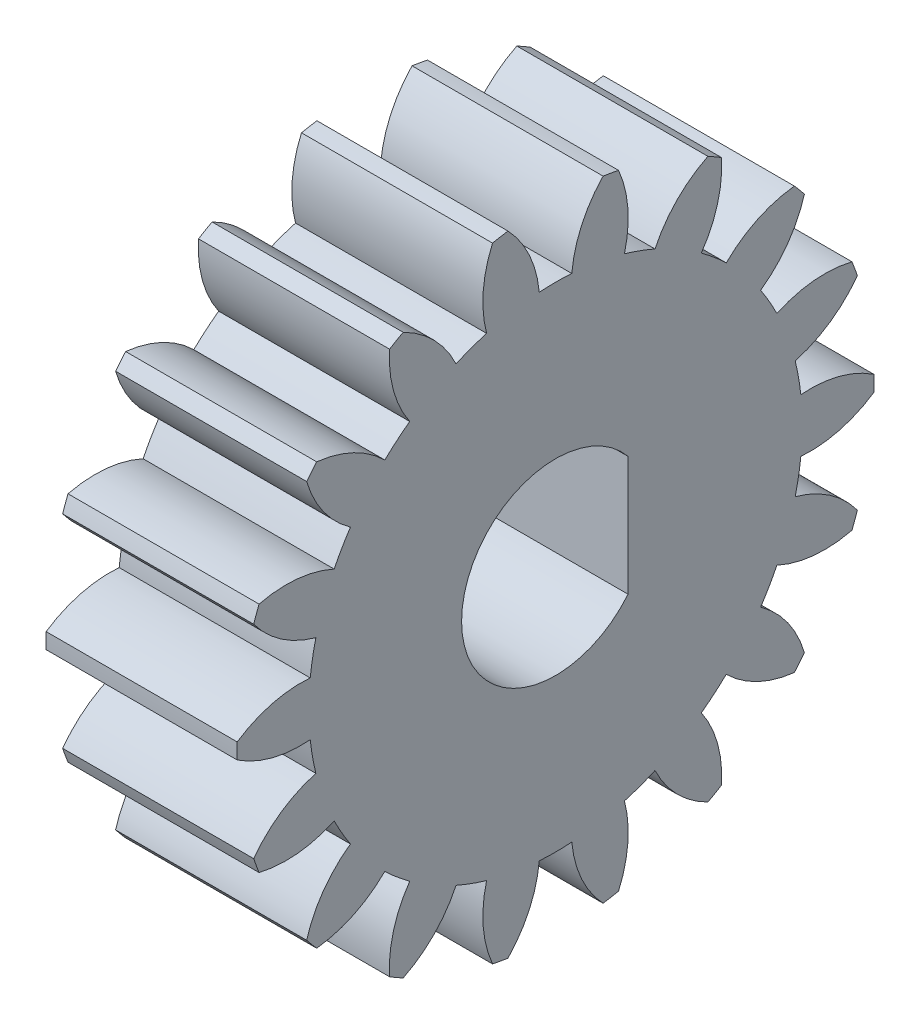
from build123d import *

# Parameters (mm, degrees)
BASPROSKE_W        = 6
BASPROSKE_H        = 10
TOOTHCUT_DEPTH     = 16.362291496
TEETHCUTS_COUNT    = 18
TEETHCUTS_ANGLE    = 340
CUT_EXTRUDE1_DEPTH = 16.289512146


with BuildPart() as part:
    # BasProSke → Base-Revolve (revolve)
    with BuildSketch(Plane(origin=(0, 0, 0), x_dir=(1, 0, 0), z_dir=(0, 1, 0)), mode=Mode.PRIVATE) as base_revolve_sk:
        with Locations((3, 5)):
            Rectangle(BASPROSKE_W, BASPROSKE_H)
    revolve(base_revolve_sk.sketch.rotate(Axis((-10, 0, 0), (1, 0, 0)), 180), axis=Axis((-10, 0, 0), (1, 0, 0)))

    # TooCutSke → ToothCut (cut, through all)
    with BuildSketch(Plane(origin=(0, 0, 0), x_dir=(0, 0, -1), z_dir=(1, 0, 0))):
        with BuildLine():
            ThreePointArc((0.510641536, 7.732156635), (0, 7.749), (-0.510641536, 7.732156635))
            ThreePointArc((-0.510641536, 7.732156635), (-0.82619259, 8.907320741), (-1.515208602, 9.910236529))
            ThreePointArc((-1.515208602, 9.910236529), (0, 10.0254), (1.515208602, 9.910236529))
            ThreePointArc((1.515208602, 9.910236529), (0.82619259, 8.907320741), (0.510641536, 7.732156635))
        make_face()
    toothcut = extrude(amount=TOOTHCUT_DEPTH, mode=Mode.SUBTRACT)

    # TeethCuts: ToothCut ×18 about axis
    teethcuts_axis = Axis((-10, 0, 0), (1, 0, 0))
    for i in range(1, TEETHCUTS_COUNT):
        add(toothcut.rotate(teethcuts_axis, i * TEETHCUTS_ANGLE / (TEETHCUTS_COUNT - 1)), mode=Mode.SUBTRACT)

    # Sketch1 → Cut-Extrude1 (cut, through all)
    with BuildSketch(Plane(origin=(6, 0, 0), x_dir=(0, 0, -1), z_dir=(1, 0, 0))):
        with BuildLine():
            Line((2.277471185, 1.875), (2.277471185, -1.875))
            ThreePointArc((2.277471185, -1.875), (-2.95, 0), (2.277471185, 1.875))
        make_face()
    extrude(amount=-CUT_EXTRUDE1_DEPTH, mode=Mode.SUBTRACT)


solid = part.part
